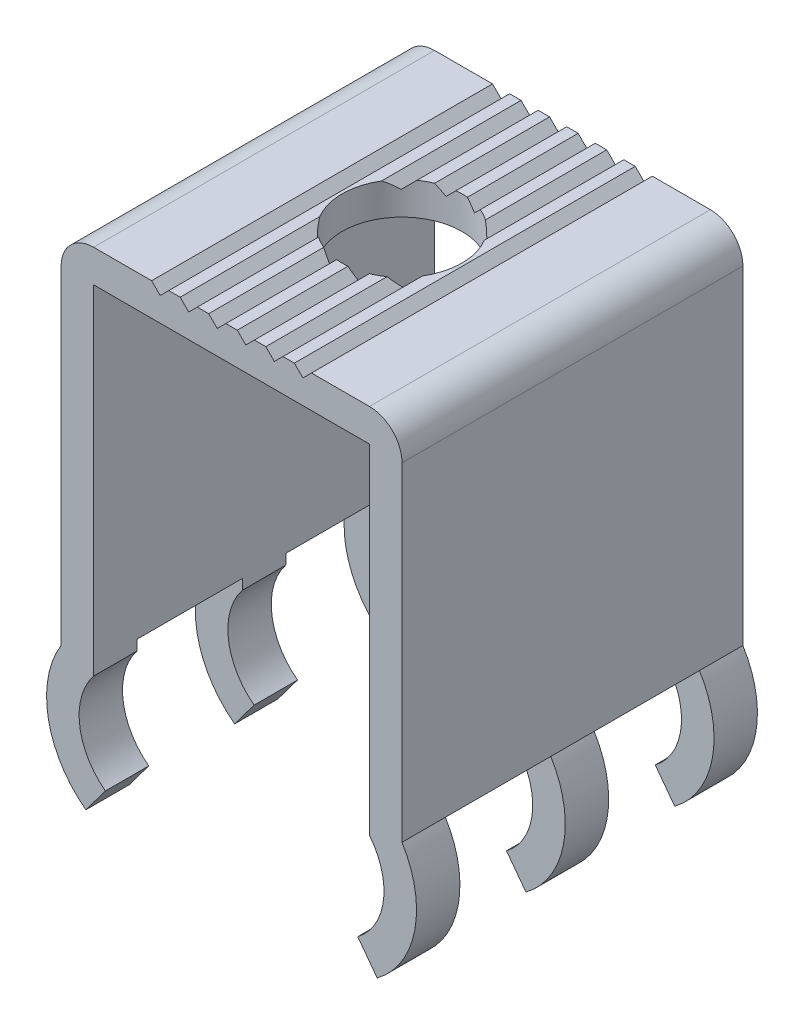
from build123d import *

# Parameters (mm, degrees)
SKETCH1_W             = 11.94
SKETCH1_H             = 11.94
BOSS_EXTRUDE1_DEPTH   = 1.14
CUT_EXTRUDE2_DEPTH    = 12.94
LPATTERN1_COUNT       = 2
LPATTERN1_PITCH       = 2
LPATTERN1_COL_COUNT   = 2
LPATTERN1_COL_PITCH   = 2
SKETCH7_W             = 1.14
SKETCH7_H             = 11.94
BOSS_EXTRUDE2_DEPTH   = 11.51
BOSS_EXTRUDE3_DEPTH   = 1.52
LPATTERN3_COUNT       = 3
LPATTERN3_PITCH       = 5.21
MIRROR1_COPY_1_DEPTH  = 1.52
MIRROR1_COPY_2_DEPTH  = 1.52
FILLET2_R             = 1.14
M5X0_8_TAPPED_HOLE2_D = 4.2


with BuildPart() as part:
    # Sketch1 → Boss-Extrude1 (new body)
    with BuildSketch(Plane(origin=(0, 0, 0), x_dir=(1, 0, 0), z_dir=(0, 1, 0))):
        Rectangle(SKETCH1_W, SKETCH1_H)
    extrude(amount=BOSS_EXTRUDE1_DEPTH)

    # Sketch4 → Cut-Extrude2 (cut, through all)
    with BuildSketch(Plane.XY.offset(5.97)):
        Polygon((0.2, 1.14), (0.5, 0.84), (0.8, 1.14), align=None)
        Polygon((-0.5, 0.84), (-0.2, 1.14), (-0.8, 1.14), align=None)
    cut_extrude2 = extrude(amount=-CUT_EXTRUDE2_DEPTH, mode=Mode.SUBTRACT)

    # LPattern1: Cut-Extrude2 ×2
    with Locations(*[(i * LPATTERN1_PITCH, 0, 0) for i in range(1, LPATTERN1_COUNT)]):
        add(cut_extrude2, mode=Mode.SUBTRACT)

    # LPattern1 col: Cut-Extrude2 ×2
    with Locations(*[(-i * LPATTERN1_COL_PITCH, 0, 0) for i in range(1, LPATTERN1_COL_COUNT)]):
        add(cut_extrude2, mode=Mode.SUBTRACT)

    # Sketch7 → Boss-Extrude2 (add)
    with BuildSketch(Plane.XZ):
        with Locations((-5.4, 0)):
            Rectangle(SKETCH7_W, SKETCH7_H)
        with Locations((5.4, 0)):
            Rectangle(SKETCH7_W, SKETCH7_H)
    extrude(amount=BOSS_EXTRUDE2_DEPTH)

    # Sketch6 → Boss-Extrude3 (add)
    with BuildSketch(Plane.XY.offset(5.97)):
        with BuildLine():
            Line((-4.83, -11.51), (-4.83, -11.86806677))
            ThreePointArc((-4.83, -11.86806677), (-5.321138867, -13.595029247), (-4.418877615, -15.14729901))
            Line((-4.418877615, -15.14729901), (-5.101941963, -16.06))
            ThreePointArc((-5.101941963, -16.06), (-6.41810343, -13.95329498), (-5.97, -11.51))
            Line((-5.97, -11.51), (-4.83, -11.51))
        make_face()
    boss_extrude3 = extrude(amount=-BOSS_EXTRUDE3_DEPTH)

    # LPattern3: Boss-Extrude3 ×3
    with Locations(*[(0, 0, -i * LPATTERN3_PITCH) for i in range(1, LPATTERN3_COUNT)]):
        add(boss_extrude3)

    # Mirror1: Boss-Extrude3 across plane
    add(boss_extrude3.mirror(Plane(origin=(0, 0, 0), x_dir=(0, 0, 1), z_dir=(1, 0, 0))))

    # Mirror1 copy 1 sketch → Mirror1 copy 1 (add)
    with BuildSketch(Plane(origin=(0, 0, 0.76), x_dir=(-1, 0, 0), z_dir=(0, 0, 1))):
        with BuildLine():
            Line((-4.83, 11.51), (-4.83, 11.86806677))
            ThreePointArc((-4.83, 11.86806677), (-5.321138867, 13.595029247), (-4.418877615, 15.14729901))
            Line((-4.418877615, 15.14729901), (-5.101941963, 16.06))
            ThreePointArc((-5.101941963, 16.06), (-6.41810343, 13.95329498), (-5.97, 11.51))
            Line((-5.97, 11.51), (-4.83, 11.51))
        make_face()
    extrude(amount=-MIRROR1_COPY_1_DEPTH)

    # Mirror1 copy 2 sketch → Mirror1 copy 2 (add)
    with BuildSketch(Plane(origin=(0, 0, -4.45), x_dir=(-1, 0, 0), z_dir=(0, 0, 1))):
        with BuildLine():
            Line((-4.83, 11.51), (-4.83, 11.86806677))
            ThreePointArc((-4.83, 11.86806677), (-5.321138867, 13.595029247), (-4.418877615, 15.14729901))
            Line((-4.418877615, 15.14729901), (-5.101941963, 16.06))
            ThreePointArc((-5.101941963, 16.06), (-6.41810343, 13.95329498), (-5.97, 11.51))
            Line((-5.97, 11.51), (-4.83, 11.51))
        make_face()
    extrude(amount=-MIRROR1_COPY_2_DEPTH)

    # Fillet2
    fillet2_edges = [part.edges().sort_by_distance(p)[0] for p in [
        (5.97, 1.14, 0),
        (-5.97, 1.14, 0),
    ]]
    fillet(fillet2_edges, radius=FILLET2_R)

    # M5x0.8 Tapped Hole2 (through all)
    with Locations(Plane.XZ):
        with Locations((0, 0)):
            Hole(M5X0_8_TAPPED_HOLE2_D / 2)


solid = part.part
